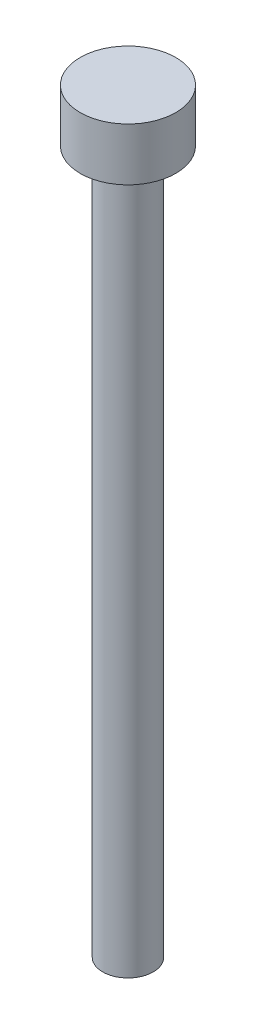
from build123d import *

# Parameters (mm, degrees)
SKETCH1_R           = 2.72
BOSS_EXTRUDE1_DEPTH = 3
SKETCH2_R           = 1.44
BOSS_EXTRUDE2_DEPTH = 40


with BuildPart() as part:
    # Sketch1 → Boss-Extrude1 (new body)
    with BuildSketch(Plane(origin=(0, 0, 0), x_dir=(1, 0, 0), z_dir=(0, 1, 0))):
        Circle(SKETCH1_R)
    extrude(amount=BOSS_EXTRUDE1_DEPTH)

    # Sketch2 → Boss-Extrude2 (add)
    with BuildSketch(Plane.XZ):
        Circle(SKETCH2_R)
    extrude(amount=BOSS_EXTRUDE2_DEPTH)


solid = part.part
